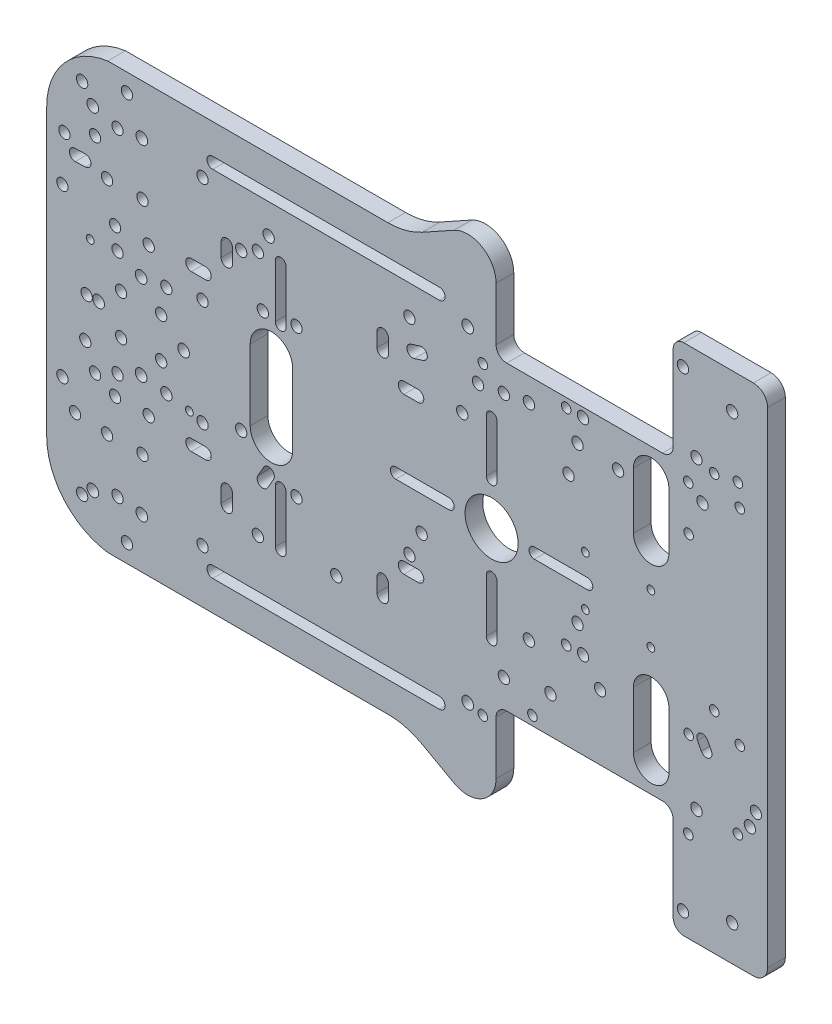
from build123d import *

# Parameters (mm, degrees)
SKETCH_1_R          = 1.6
SKETCH_1_R_2        = 1.35
SKETCH_1_R_3        = 1.1
SKETCH_1_R_4        = 7.5
EXTRUDE_1_DEPTH     = 5
SKETCH_2_R          = 1.65
CUT_EXTRUDE_1_DEPTH = 10
SKETCH_3_R          = 1.65
CUT_EXTRUDE_2_DEPTH = 10
FILLET_1_R          = 4
FILLET_2_R          = 8
FILLET_3_R          = 20
SKETCH_4_R          = 1.65
CUT_EXTRUDE_3_DEPTH = 10
CUT_EXTRUDE_4_DEPTH = 10


with BuildPart() as part:
    # 草图1 → 凸台-拉伸1 (new body)
    with BuildSketch(Plane(origin=(0, 0, -5), x_dir=(-1, 0, 0), z_dir=(0, 0, -1))):
        with BuildLine():
            Line((-25.098291392, 69.5), (-25.098291392, 45.53))
            ThreePointArc((-25.098291392, 45.53), (-25.976971049, 43.408679656), (-28.098291392, 42.53))
            Line((-28.098291392, 42.53), (-72.098291392, 42.53))
            ThreePointArc((-72.098291392, 42.53), (-74.219611736, 43.408679656), (-75.098291392, 45.53))
            Line((-75.098291392, 45.53), (-75.098291392, 69.5))
            ThreePointArc((-75.098291392, 69.5), (-75.976971049, 71.621320344), (-78.098291392, 72.5))
            Line((-78.098291392, 72.5), (-81.75, 72.5))
            Line((-81.75, 72.5), (-101.75, 72.5))
            Line((-101.75, 72.5), (-101.75, 52.5))
            Line((-101.75, 52.5), (-101.75, -52.5))
            Line((-101.75, -52.5), (-101.75, -72.5))
            Line((-101.75, -72.5), (-81.75, -72.5))
            Line((-81.75, -72.5), (-78.098291392, -72.5))
            ThreePointArc((-78.098291392, -72.5), (-75.976971049, -71.621320344), (-75.098291392, -69.5))
            Line((-75.098291392, -69.5), (-75.098291392, -45.53))
            ThreePointArc((-75.098291392, -45.53), (-74.219611736, -43.408679656), (-72.098291392, -42.53))
            Line((-72.098291392, -42.53), (-28.098291392, -42.53))
            ThreePointArc((-28.098291392, -42.53), (-25.976971049, -43.408679656), (-25.098291392, -45.53))
            Line((-25.098291392, -45.53), (-25.098291392, -69.5))
            Line((-25.098291392, -69.5), (-25.098291392, -74.166179813))
            Line((-25.098291392, -74.166179813), (-22.098291392, -72.5))
            Line((-22.098291392, -72.5), (0.258343892, -60.083275199))
            Line((0.258343892, -60.083275199), (84.521608831, -60.083275199))
            ThreePointArc((84.521608831, -60.083275199), (96.840264687, -53.401948201), (101.75, -40.276251584))
            Line((101.75, -40.276251584), (101.75, 40.276251584))
            ThreePointArc((101.75, 40.276251584), (96.840264687, 53.401948201), (84.521608831, 60.083275199))
            Line((84.521608831, 60.083275199), (0.258343892, 60.083275199))
            Line((0.258343892, 60.083275199), (-22.098291392, 72.5))
            Line((-22.098291392, 72.5), (-25.098291392, 74.166179813))
            Line((-25.098291392, 74.166179813), (-25.098291392, 69.5))
        make_face()
        with Locations((-27.29868251, -34.718942956)):
            Circle(SKETCH_1_R, mode=Mode.SUBTRACT)
        with Locations((42.139203403, -34.718942956)):
            Circle(SKETCH_1_R, mode=Mode.SUBTRACT)
        with Locations((42.139203403, 34.718942956)):
            Circle(SKETCH_1_R, mode=Mode.SUBTRACT)
        with Locations((-27.29868251, 34.718942956)):
            Circle(SKETCH_1_R, mode=Mode.SUBTRACT)
        with Locations((81.75, -45)):
            Circle(SKETCH_1_R, mode=Mode.SUBTRACT)
        with Locations((88.1, -18)):
            Circle(SKETCH_1_R, mode=Mode.SUBTRACT)
        with Locations((79.100997925, -55)):
            Circle(SKETCH_1_R, mode=Mode.SUBTRACT)
        with Locations((93.75, -30.5)):
            Circle(SKETCH_1_R, mode=Mode.SUBTRACT)
        with Locations((91.75, -49.5)):
            Circle(SKETCH_1_R, mode=Mode.SUBTRACT)
        with Locations((-4.092359364, -11.071587139)):
            Circle(SKETCH_1_R, mode=Mode.SUBTRACT)
        with Locations((-0.65, -18)):
            Circle(SKETCH_1_R, mode=Mode.SUBTRACT)
        with Locations((31.236601149, -19.859650045)):
            Circle(SKETCH_1_R, mode=Mode.SUBTRACT)
        with Locations((20, -33.5)):
            Circle(SKETCH_1_R, mode=Mode.SUBTRACT)
        with Locations((-21.356773347, -46.957974948)):
            Circle(SKETCH_1_R_2, mode=Mode.SUBTRACT)
        with Locations((57.75, -45)):
            Circle(SKETCH_1_R, mode=Mode.SUBTRACT)
        with Locations((31.236601149, 21.859650045)):
            Circle(SKETCH_1_R, mode=Mode.SUBTRACT)
        with Locations((46.850827718, 32.6)):
            Circle(SKETCH_1_R, mode=Mode.SUBTRACT)
        with Locations((39.1, 40)):
            Circle(SKETCH_1_R, mode=Mode.SUBTRACT)
        with Locations((-15.547078361, 24.122234231)):
            Circle(SKETCH_1_R, mode=Mode.SUBTRACT)
        with Locations((-21.356773347, 39.042025052)):
            Circle(SKETCH_1_R_2, mode=Mode.SUBTRACT)
        with Locations((-20, 33.5)):
            Circle(SKETCH_1_R, mode=Mode.SUBTRACT)
        with Locations((-0.65, 40)):
            Circle(SKETCH_1_R, mode=Mode.SUBTRACT)
        with Locations((57.75, -15)):
            Circle(SKETCH_1_R, mode=Mode.SUBTRACT)
        with Locations((81.75, -15)):
            Circle(SKETCH_1_R, mode=Mode.SUBTRACT)
        with Locations((90.850827718, -11.4)):
            Circle(SKETCH_1_R, mode=Mode.SUBTRACT)
        with Locations((57.75, 45)):
            Circle(SKETCH_1_R, mode=Mode.SUBTRACT)
        with Locations((81.75, 45)):
            Circle(SKETCH_1_R, mode=Mode.SUBTRACT)
        with Locations((88.1, 40)):
            Circle(SKETCH_1_R, mode=Mode.SUBTRACT)
        with Locations((81.75, 15)):
            Circle(SKETCH_1_R, mode=Mode.SUBTRACT)
        with Locations((57.75, 15)):
            Circle(SKETCH_1_R, mode=Mode.SUBTRACT)
        with Locations((46.850827718, -11.4)):
            Circle(SKETCH_1_R, mode=Mode.SUBTRACT)
        with Locations((96.75, 36.5)):
            Circle(SKETCH_1_R, mode=Mode.SUBTRACT)
        with Locations((79.100997925, 55)):
            Circle(SKETCH_1_R, mode=Mode.SUBTRACT)
        with Locations((91.75, 51.5)):
            Circle(SKETCH_1_R, mode=Mode.SUBTRACT)
        with Locations((-68.8, -6.599745999)):
            Circle(SKETCH_1_R_3, mode=Mode.SUBTRACT)
        with Locations((-68.8, 7.400254001)):
            Circle(SKETCH_1_R_3, mode=Mode.SUBTRACT)
        with Locations((-79.470199179, 26.47078378)):
            Circle(SKETCH_1_R_2, mode=Mode.SUBTRACT)
        with Locations((-48.092359364, 32.928412861)):
            Circle(SKETCH_1_R, mode=Mode.SUBTRACT)
        with Locations((-59.547078361, 32.122234231)):
            Circle(SKETCH_1_R, mode=Mode.SUBTRACT)
        with Locations((-93.9, 40)):
            Circle(SKETCH_1_R_2, mode=Mode.SUBTRACT)
        with Locations((-79.356773347, 39.042025052)):
            Circle(SKETCH_1_R_2, mode=Mode.SUBTRACT)
        with Locations((-44.9, 40)):
            Circle(SKETCH_1_R_2, mode=Mode.SUBTRACT)
        with Locations((-49.65, 40)):
            Circle(SKETCH_1_R, mode=Mode.SUBTRACT)
        with Locations((-91.75, 62.5)):
            Circle(SKETCH_1_R, mode=Mode.SUBTRACT)
        with Locations((-83.368894541, 35.966393695)):
            Circle(SKETCH_1_R, mode=Mode.SUBTRACT)
        with Locations((-77.857400894, 66.5)):
            Circle(SKETCH_1_R, mode=Mode.SUBTRACT)
        with Locations((-86.675021179, 44.84592378)):
            Circle(SKETCH_1_R_2, mode=Mode.SUBTRACT)
        with Locations((-79.356773347, -46.957974948)):
            Circle(SKETCH_1_R_2, mode=Mode.SUBTRACT)
        with Locations((-81.677739729, -39.803136329)):
            Circle(SKETCH_1_R, mode=Mode.SUBTRACT)
        with Locations((-35.356773347, -39.957974948)):
            Circle(SKETCH_1_R_2, mode=Mode.SUBTRACT)
        with Locations((-34.368992541, -22.033490305)):
            Circle(SKETCH_1_R, mode=Mode.SUBTRACT)
        with Locations((-93.356773347, -39.957974948)):
            Circle(SKETCH_1_R_2, mode=Mode.SUBTRACT)
        with Locations((-91.75, -62.5)):
            Circle(SKETCH_1_R, mode=Mode.SUBTRACT)
        with Locations((-77.857400894, -66.5)):
            Circle(SKETCH_1_R, mode=Mode.SUBTRACT)
        with Locations((-40.452925, -32.122234231)):
            Circle(SKETCH_1_R, mode=Mode.SUBTRACT)
        with Locations((-98.452925, -32.122234231)):
            Circle(SKETCH_1_R, mode=Mode.SUBTRACT)
        with Locations((-79.470199179, -22.52911822)):
            Circle(SKETCH_1_R_2, mode=Mode.SUBTRACT)
        with Locations((-96.75, -36.5)):
            Circle(SKETCH_1_R, mode=Mode.SUBTRACT)
        with Locations((-93.356773347, 46.042025052)):
            Circle(SKETCH_1_R_2, mode=Mode.SUBTRACT)
        with Locations((-81.677739729, 46.196863671)):
            Circle(SKETCH_1_R, mode=Mode.SUBTRACT)
        with Locations((-86.675021179, -13.15396022)):
            Circle(SKETCH_1_R_2, mode=Mode.SUBTRACT)
        with Locations((-93.9, -18)):
            Circle(SKETCH_1_R_2, mode=Mode.SUBTRACT)
        with Locations((-48.092359364, -11.071587139)):
            Circle(SKETCH_1_R, mode=Mode.SUBTRACT)
        with Locations((-50.300127, -6.599745999)):
            Circle(SKETCH_1_R_3, mode=Mode.SUBTRACT)
        with Locations((-50.300127, 7.400254001)):
            Circle(SKETCH_1_R_3, mode=Mode.SUBTRACT)
        with Locations((-49.65, -18)):
            Circle(SKETCH_1_R, mode=Mode.SUBTRACT)
        with Locations((-45.547078361, 24.122234231)):
            Circle(SKETCH_1_R, mode=Mode.SUBTRACT)
        with Locations((-44.9, -18)):
            Circle(SKETCH_1_R_2, mode=Mode.SUBTRACT)
        with Locations((-54.452925, -24.122234231)):
            Circle(SKETCH_1_R, mode=Mode.SUBTRACT)
        with Locations((-34.368992541, 35.966393695)):
            Circle(SKETCH_1_R, mode=Mode.SUBTRACT)
        with Locations((80.753105443, 5.656854249)):
            Circle(SKETCH_1_R, mode=Mode.SUBTRACT)
        with Locations((82.455901239, 20.859650045)):
            Circle(SKETCH_1_R, mode=Mode.SUBTRACT)
        with Locations((89.47088481, 14.001428535)):
            Circle(SKETCH_1_R_3, mode=Mode.SUBTRACT)
        with Locations((67.970170542, 12.989666789)):
            Circle(SKETCH_1_R, mode=Mode.SUBTRACT)
        with Locations((97.318352655, 23.5)):
            Circle(SKETCH_1_R, mode=Mode.SUBTRACT)
        with Locations((40.736601149, 20.859650045)):
            Circle(SKETCH_1_R, mode=Mode.SUBTRACT)
        with Locations((72.955901239, 20.859650045)):
            Circle(SKETCH_1_R, mode=Mode.SUBTRACT)
        with Locations((74.705709954, -31.2)):
            Circle(SKETCH_1_R, mode=Mode.SUBTRACT)
        with Locations((72.955901239, -20.859650045)):
            Circle(SKETCH_1_R, mode=Mode.SUBTRACT)
        with Locations((74.705709954, 31.2)):
            Circle(SKETCH_1_R, mode=Mode.SUBTRACT)
        with Locations((67.970170542, -12.989666789)):
            Circle(SKETCH_1_R, mode=Mode.SUBTRACT)
        with Locations((69.439396944, 5.656854249)):
            Circle(SKETCH_1_R, mode=Mode.SUBTRACT)
        with Locations((80.753105443, -5.656854249)):
            Circle(SKETCH_1_R, mode=Mode.SUBTRACT)
        with Locations((84.705209992, -31.2)):
            Circle(SKETCH_1_R, mode=Mode.SUBTRACT)
        with Locations((90.470170542, 0.000714267)):
            Circle(SKETCH_1_R, mode=Mode.SUBTRACT)
        with Locations((69.439396944, -5.656854249)):
            Circle(SKETCH_1_R, mode=Mode.SUBTRACT)
        with Locations((84.705209992, 31.2)):
            Circle(SKETCH_1_R, mode=Mode.SUBTRACT)
        with Locations((82.455901239, -20.859650045)):
            Circle(SKETCH_1_R, mode=Mode.SUBTRACT)
        with Locations((61.469456275, -14)):
            Circle(SKETCH_1_R_3, mode=Mode.SUBTRACT)
        with Locations((97.318352655, -23.5)):
            Circle(SKETCH_1_R, mode=Mode.SUBTRACT)
        with Locations((-23.838865916, 0)):
            Circle(SKETCH_1_R_4, mode=Mode.SUBTRACT)
        with BuildLine():
            Line((-2.030199302, 30.596916508), (-4.575480304, 31.403095137))
            ThreePointArc((-4.575480304, 31.403095137), (-5.617677087, 33.411533801), (-3.609238424, 34.453730584))
            Line((-3.609238424, 34.453730584), (-1.063957421, 33.647551954))
            ThreePointArc((-1.063957421, 33.647551954), (-0.021760638, 31.639113291), (-2.030199302, 30.596916508))
        make_face(mode=Mode.SUBTRACT)
        with BuildLine():
            Line((93.694844635, 30.900950943), (90.795672353, 31.000950943))
            ThreePointArc((90.795672353, 31.000950943), (89.251778661, 32.655155365), (90.905983083, 34.199049057))
            Line((90.905983083, 34.199049057), (93.805155365, 34.099049057))
            ThreePointArc((93.805155365, 34.099049057), (95.349049057, 32.444844635), (93.694844635, 30.900950943))
        make_face(mode=Mode.SUBTRACT)
        with BuildLine():
            Line((-85.873060411, -23.385202744), (-84.789029952, -21.296458817))
            ThreePointArc((-84.789029952, -21.296458817), (-82.631863053, -20.613354893), (-81.948759129, -22.770521792))
            Line((-81.948759129, -22.770521792), (-83.032789588, -24.859265718))
            ThreePointArc((-83.032789588, -24.859265718), (-85.189956487, -25.542369643), (-85.873060411, -23.385202744))
        make_face(mode=Mode.SUBTRACT)
        with BuildLine():
            Line((40.488662539, -17.205257052), (42.125263688, -20.064907097))
            ThreePointArc((42.125263688, -20.064907097), (41.531344097, -22.248312584), (39.34793861, -21.654392993))
            Line((39.34793861, -21.654392993), (37.711337461, -18.794742948))
            ThreePointArc((37.711337461, -18.794742948), (38.305257052, -16.611337461), (40.488662539, -17.205257052))
        make_face(mode=Mode.SUBTRACT)
        with BuildLine():
            Line((-63.882602692, 34.796863671), (-63.882602692, 18.796863671))
            ThreePointArc((-63.882602692, 18.796863671), (-68.882602692, 13.796863671), (-73.882602692, 18.796863671))
            Line((-73.882602692, 18.796863671), (-73.882602692, 34.796863671))
            ThreePointArc((-73.882602692, 34.796863671), (-68.882602692, 39.796863671), (-63.882602692, 34.796863671))
        make_face(mode=Mode.SUBTRACT)
        with BuildLine():
            Line((-73.882602692, -34.796863671), (-73.882602692, -18.796863671))
            ThreePointArc((-73.882602692, -18.796863671), (-68.882602692, -13.796863671), (-63.882602692, -18.796863671))
            Line((-63.882602692, -18.796863671), (-63.882602692, -34.796863671))
            ThreePointArc((-63.882602692, -34.796863671), (-68.882602692, -39.796863671), (-73.882602692, -34.796863671))
        make_face(mode=Mode.SUBTRACT)
        with BuildLine():
            Line((-35.90679423, -1.5), (-50.90679423, -1.5))
            ThreePointArc((-50.90679423, -1.5), (-52.40679423, 0), (-50.90679423, 1.5))
            Line((-50.90679423, 1.5), (-35.90679423, 1.5))
            ThreePointArc((-35.90679423, 1.5), (-34.40679423, 0), (-35.90679423, -1.5))
        make_face(mode=Mode.SUBTRACT)
        with BuildLine():
            Line((-11.770937602, 1.5), (3.229062398, 1.5))
            ThreePointArc((3.229062398, 1.5), (4.729062398, 0), (3.229062398, -1.5))
            Line((3.229062398, -1.5), (-11.770937602, -1.5))
            ThreePointArc((-11.770937602, -1.5), (-13.270937602, 0), (-11.770937602, 1.5))
        make_face(mode=Mode.SUBTRACT)
        with BuildLine():
            Line((-25.338865916, 12.067928314), (-25.338865916, 27.067928314))
            ThreePointArc((-25.338865916, 27.067928314), (-23.838865916, 28.567928314), (-22.338865916, 27.067928314))
            Line((-22.338865916, 27.067928314), (-22.338865916, 12.067928314))
            ThreePointArc((-22.338865916, 12.067928314), (-23.838865916, 10.567928314), (-25.338865916, 12.067928314))
        make_face(mode=Mode.SUBTRACT)
        with BuildLine():
            Line((-25.338865916, -27.067928314), (-25.338865916, -12.067928314))
            ThreePointArc((-25.338865916, -12.067928314), (-23.838865916, -10.567928314), (-22.338865916, -12.067928314))
            Line((-22.338865916, -12.067928314), (-22.338865916, -27.067928314))
            ThreePointArc((-22.338865916, -27.067928314), (-23.838865916, -28.567928314), (-25.338865916, -27.067928314))
        make_face(mode=Mode.SUBTRACT)
        with BuildLine():
            Line((37.213478088, -20), (37.213478088, -35))
            ThreePointArc((37.213478088, -35), (35.713478088, -36.5), (34.213478088, -35))
            Line((34.213478088, -35), (34.213478088, -20))
            ThreePointArc((34.213478088, -20), (35.713478088, -18.5), (37.213478088, -20))
        make_face(mode=Mode.SUBTRACT)
        with BuildLine():
            Line((44.304609404, 11), (44.304609404, -9))
            ThreePointArc((44.304609404, -9), (38.304609404, -15), (32.304609404, -9))
            Line((32.304609404, -9), (32.304609404, 11))
            ThreePointArc((32.304609404, 11), (38.304609404, 17), (44.304609404, 11))
        make_face(mode=Mode.SUBTRACT)
        with BuildLine():
            Line((34.213478088, 20), (34.213478088, 35))
            ThreePointArc((34.213478088, 35), (35.713478088, 36.5), (37.213478088, 35))
            Line((37.213478088, 35), (37.213478088, 20))
            ThreePointArc((37.213478088, 20), (35.713478088, 18.5), (34.213478088, 20))
        make_face(mode=Mode.SUBTRACT)
    extrude(amount=-EXTRUDE_1_DEPTH)

    # 草图2 → 切除-拉伸1 (cut)
    with BuildSketch(Plane(origin=(0, 0, -5), x_dir=(-1, 0, 0), z_dir=(0, 0, -1))):
        with Locations((75.096251194, 12)):
            Circle(SKETCH_2_R)
        with Locations((87.096251194, 0)):
            Circle(SKETCH_2_R)
        with Locations((75.096251194, -12)):
            Circle(SKETCH_2_R)
        with Locations((63.096251194, 0)):
            Circle(SKETCH_2_R)
    extrude(amount=-CUT_EXTRUDE_1_DEPTH, mode=Mode.SUBTRACT)

    # 草图3 → 切除-拉伸2 (cut)
    with BuildSketch(Plane(origin=(0, 0, -5), x_dir=(-1, 0, 0), z_dir=(0, 0, -1))):
        with Locations((88.75, 47)):
            Circle(SKETCH_3_R)
        with Locations((88.75, -47)):
            Circle(SKETCH_3_R)
    extrude(amount=-CUT_EXTRUDE_2_DEPTH, mode=Mode.SUBTRACT)

    # 圆角1
    fillet_1_edges = [part.edges().sort_by_distance(p)[0] for p in [
        (101.75, -72.5, -2.5),
        (101.75, 72.5, -2.5),
    ]]
    fillet(fillet_1_edges, radius=FILLET_1_R)

    # 圆角2
    fillet_2_edges = [part.edges().sort_by_distance(p)[0] for p in [
        (25.098291392, -74.166179813, -2.5),
        (25.098291392, 74.166179813, -2.5),
    ]]
    fillet(fillet_2_edges, radius=FILLET_2_R)

    # 圆角3
    fillet_3_edges = [part.edges().sort_by_distance(p)[0] for p in [
        (-0.258343892, 60.083275199, -2.5),
        (-0.258343892, -60.083275199, -2.5),
    ]]
    fillet(fillet_3_edges, radius=FILLET_3_R)

    # 草图4 → 切除-拉伸3 (cut)
    with BuildSketch(Plane(origin=(0, 0, -5), x_dir=(-1, 0, 0), z_dir=(0, 0, -1))):
        with Locations((-17.098291392, 46)):
            Circle(SKETCH_4_R)
        with Locations((74.901708608, 46)):
            Circle(SKETCH_4_R)
        with Locations((74.901708608, -46)):
            Circle(SKETCH_4_R)
        with Locations((-17.098291392, -46)):
            Circle(SKETCH_4_R)
        with BuildLine():
            Line((8.501708608, 32), (8.501708608, 28))
            ThreePointArc((8.501708608, 28), (6.901708608, 26.4), (5.301708608, 28))
            Line((5.301708608, 28), (5.301708608, 32))
            ThreePointArc((5.301708608, 32), (6.901708608, 33.6), (8.501708608, 32))
        make_face()
        with BuildLine():
            Line((-3.098291392, 23.6), (0.901708608, 23.6))
            ThreePointArc((0.901708608, 23.6), (2.501708608, 22), (0.901708608, 20.4))
            Line((0.901708608, 20.4), (-3.098291392, 20.4))
            ThreePointArc((-3.098291392, 20.4), (-4.698291392, 22), (-3.098291392, 23.6))
        make_face()
        with BuildLine():
            Line((60.901708608, 23.6), (56.901708608, 23.6))
            ThreePointArc((56.901708608, 23.6), (55.301708608, 22), (56.901708608, 20.4))
            Line((56.901708608, 20.4), (60.901708608, 20.4))
            ThreePointArc((60.901708608, 20.4), (62.501708608, 22), (60.901708608, 23.6))
        make_face()
        with BuildLine():
            Line((49.301708608, 32), (49.301708608, 28))
            ThreePointArc((49.301708608, 28), (50.901708608, 26.4), (52.501708608, 28))
            Line((52.501708608, 28), (52.501708608, 32))
            ThreePointArc((52.501708608, 32), (50.901708608, 33.6), (49.301708608, 32))
        make_face()
        with BuildLine():
            Line((60.901708608, -23.6), (56.901708608, -23.6))
            ThreePointArc((56.901708608, -23.6), (55.301708608, -22), (56.901708608, -20.4))
            Line((56.901708608, -20.4), (60.901708608, -20.4))
            ThreePointArc((60.901708608, -20.4), (62.501708608, -22), (60.901708608, -23.6))
        make_face()
        with BuildLine():
            Line((49.301708608, -32), (49.301708608, -28))
            ThreePointArc((49.301708608, -28), (50.901708608, -26.4), (52.501708608, -28))
            Line((52.501708608, -28), (52.501708608, -32))
            ThreePointArc((52.501708608, -32), (50.901708608, -33.6), (49.301708608, -32))
        make_face()
        with BuildLine():
            Line((-3.098291392, -23.6), (0.901708608, -23.6))
            ThreePointArc((0.901708608, -23.6), (2.501708608, -22), (0.901708608, -20.4))
            Line((0.901708608, -20.4), (-3.098291392, -20.4))
            ThreePointArc((-3.098291392, -20.4), (-4.698291392, -22), (-3.098291392, -23.6))
        make_face()
        with BuildLine():
            Line((8.501708608, -32), (8.501708608, -28))
            ThreePointArc((8.501708608, -28), (6.901708608, -26.4), (5.301708608, -28))
            Line((5.301708608, -28), (5.301708608, -32))
            ThreePointArc((5.301708608, -32), (6.901708608, -33.6), (8.501708608, -32))
        make_face()
    extrude(amount=-CUT_EXTRUDE_3_DEPTH, mode=Mode.SUBTRACT)

    # 草图5 → 切除-拉伸4 (cut)
    with BuildSketch(Plane(origin=(0, 0, -5), x_dir=(-1, 0, 0), z_dir=(0, 0, -1))):
        with BuildLine():
            Line((-9.098291392, 51.6), (54.901708608, 51.6))
            ThreePointArc((54.901708608, 51.6), (56.501708608, 50), (54.901708608, 48.4))
            Line((54.901708608, 48.4), (-9.098291392, 48.4))
            ThreePointArc((-9.098291392, 48.4), (-10.698291392, 50), (-9.098291392, 51.6))
        make_face()
        with BuildLine():
            Line((-9.098291392, -51.6), (54.901708608, -51.6))
            ThreePointArc((54.901708608, -51.6), (56.501708608, -50), (54.901708608, -48.4))
            Line((54.901708608, -48.4), (-9.098291392, -48.4))
            ThreePointArc((-9.098291392, -48.4), (-10.698291392, -50), (-9.098291392, -51.6))
        make_face()
    extrude(amount=-CUT_EXTRUDE_4_DEPTH, mode=Mode.SUBTRACT)


solid = part.part
